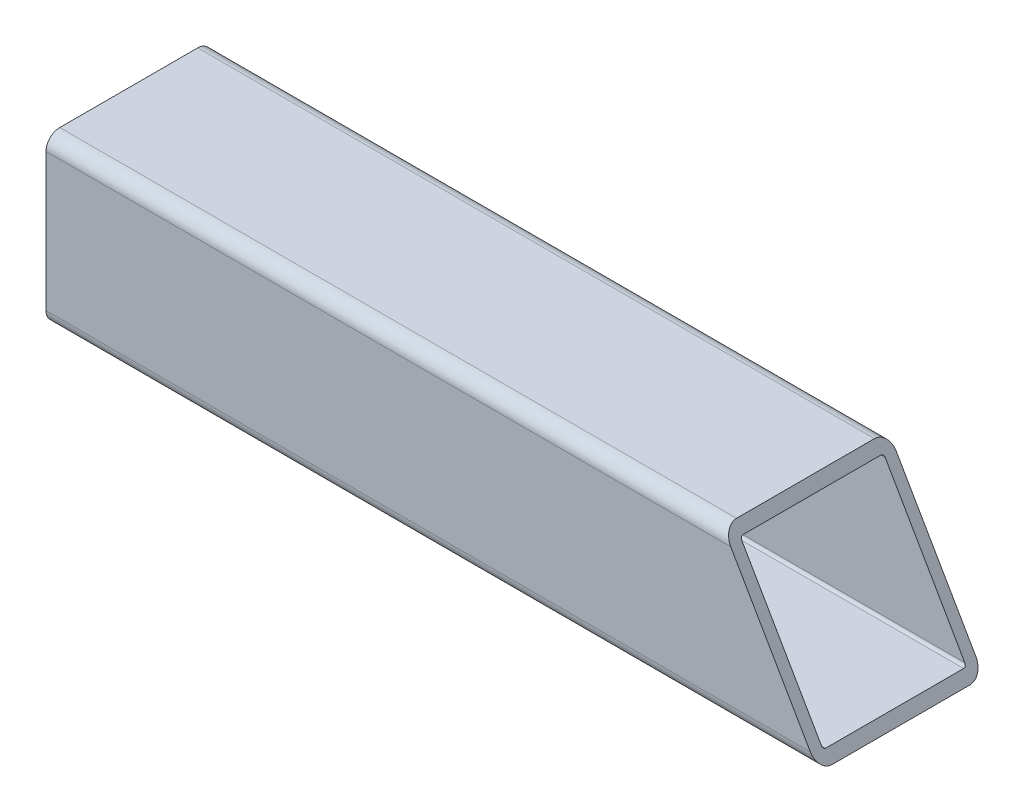
from build123d import *

# Parameters (mm, degrees)
EXTRUDE_THIN1_DEPTH     = 88.9
CUT_EXTRUDE1_DEPTH      = 1
CUT_EXTRUDE1_DEPTH_BACK = 39.1


with BuildPart() as part:
    # Sketch1 → Extrude-Thin1 (new body, symmetric)
    with BuildSketch(Plane(origin=(0, 0, 0), x_dir=(0, 0, -1), z_dir=(1, 0, 0))):
        with BuildLine():
            Line((-15.875, 19.05), (15.875, 19.05))
            ThreePointArc((15.875, 19.05), (18.12006403, 18.12006403), (19.05, 15.875))
            Line((19.05, 15.875), (19.05, -15.875))
            ThreePointArc((19.05, -15.875), (18.12006403, -18.12006403), (15.875, -19.05))
            Line((15.875, -19.05), (-15.875, -19.05))
            ThreePointArc((-15.875, -19.05), (-18.12006403, -18.12006403), (-19.05, -15.875))
            Line((-19.05, -15.875), (-19.05, 15.875))
            ThreePointArc((-19.05, 15.875), (-18.12006403, 18.12006403), (-15.875, 19.05))
        make_face()
        with BuildLine():
            Line((-15.875, 16.51), (15.875, 16.51))
            ThreePointArc((15.875, 16.51), (16.324012806, 16.324012806), (16.51, 15.875))
            Line((16.51, 15.875), (16.51, -15.875))
            ThreePointArc((16.51, -15.875), (16.324012806, -16.324012806), (15.875, -16.51))
            Line((15.875, -16.51), (-15.875, -16.51))
            ThreePointArc((-15.875, -16.51), (-16.324012806, -16.324012806), (-16.51, -15.875))
            Line((-16.51, -15.875), (-16.51, 15.875))
            ThreePointArc((-16.51, 15.875), (-16.324012806, 16.324012806), (-15.875, 16.51))
        make_face(mode=Mode.SUBTRACT)
    extrude(amount=EXTRUDE_THIN1_DEPTH, both=True)

    # Sketch2 → Cut-Extrude1 (cut, two sides)
    with BuildSketch(Plane.XY.offset(19.05)) as cut_extrude1_sk:
        Polygon((275.736327504, -342.660011936), (88.9, -19.05), (66.902954744, 19.05), (-119.93337276, 342.660011936), (527.286651112, 716.332666943), (922.956351375, 31.012643071), align=None)
    extrude(amount=CUT_EXTRUDE1_DEPTH, mode=Mode.SUBTRACT)
    extrude(cut_extrude1_sk.sketch, amount=-CUT_EXTRUDE1_DEPTH_BACK, mode=Mode.SUBTRACT)


solid = part.part
